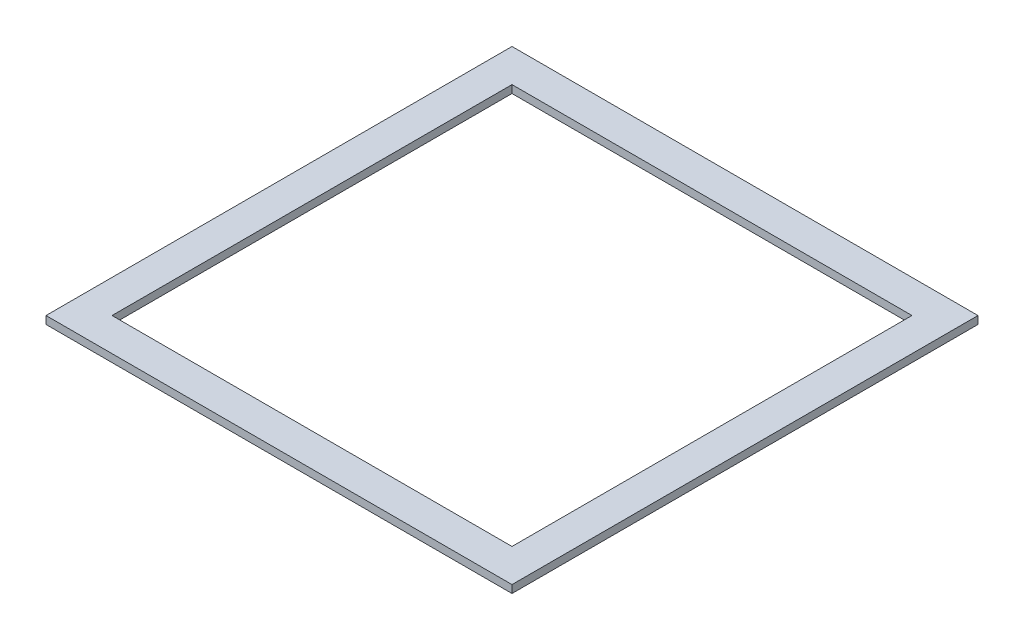
from build123d import *

# Parameters (mm, degrees)
SKETCH_1_W          = 600
SKETCH_1_H          = 600
EXTRUDE_1_DEPTH     = 10
SKETCH_2_W          = 515
SKETCH_2_H          = 515
CUT_EXTRUDE_1_DEPTH = 11


with BuildPart() as part:
    # 草图1 → 凸台-拉伸1 (new body)
    with BuildSketch(Plane(origin=(0, 0, 0), x_dir=(1, 0, 0), z_dir=(0, 1, 0))):
        Rectangle(SKETCH_1_W, SKETCH_1_H)
    extrude(amount=EXTRUDE_1_DEPTH)

    # 草图2 → 切除-拉伸1 (cut, through all)
    with BuildSketch(Plane(origin=(0, 10, 0), x_dir=(1, 0, 0), z_dir=(0, 1, 0))):
        Rectangle(SKETCH_2_W, SKETCH_2_H)
    extrude(amount=-CUT_EXTRUDE_1_DEPTH, mode=Mode.SUBTRACT)


solid = part.part
